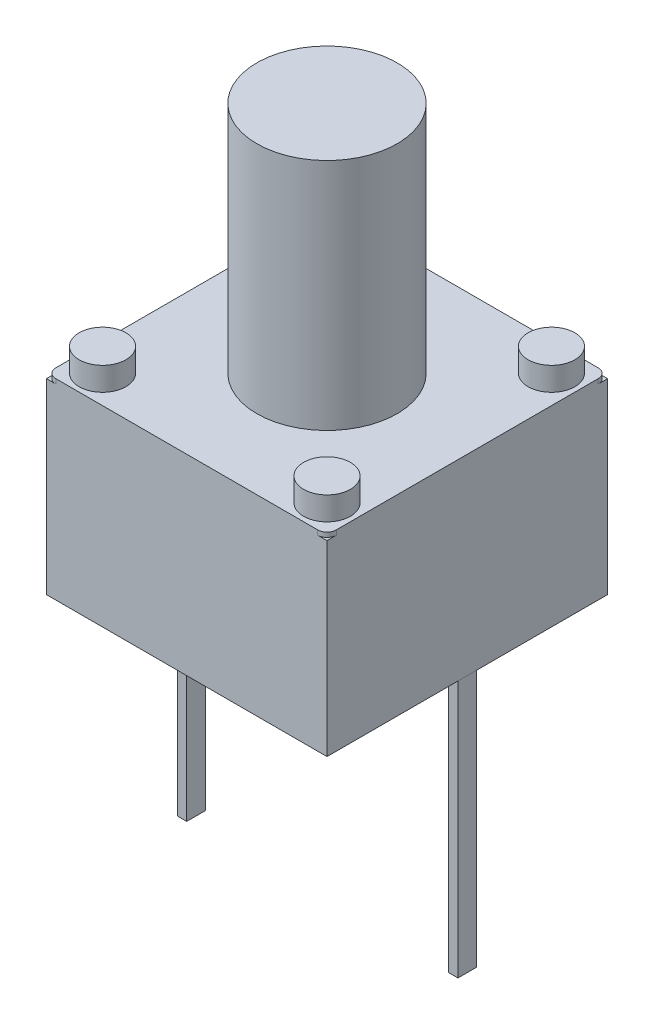
from build123d import *

# Parameters (mm, degrees)
SKETCH1_W             = 6
SKETCH1_H             = 6
BOSS_EXTRUDE1_DEPTH   = 4
BOSS_EXTRUDE2_DEPTH   = 0.1
SKETCH4_R             = 0.5
BOSS_EXTRUDE3_DEPTH   = 0.5
SKETCH5_R             = 1.5
BOSS_EXTRUDE4_DEPTH   = 5
SKETCH6_W             = 0.2
SKETCH6_H             = 0.4
BOSS_EXTRUDE5_DEPTH   = 5.5
BOSS_EXTRUDE5_2_DEPTH = 5.5


with BuildPart() as part:
    # Sketch1 → Boss-Extrude1 (new body)
    with BuildSketch(Plane(origin=(0, 0, 0), x_dir=(1, 0, 0), z_dir=(0, 1, 0))):
        with Locations((3, 3)):
            Rectangle(SKETCH1_W, SKETCH1_H)
    extrude(amount=BOSS_EXTRUDE1_DEPTH)

    # Sketch2 → Boss-Extrude2 (add)
    with BuildSketch(Plane(origin=(0, 4, 0), x_dir=(1, 0, 0), z_dir=(0, 1, 0))):
        with BuildLine():
            Line((0.2, 6), (5.8, 6))
            ThreePointArc((5.8, 6), (5.941421356, 5.941421356), (6, 5.8))
            Line((6, 5.8), (6, 0.2))
            ThreePointArc((6, 0.2), (5.941421356, 0.058578644), (5.8, 0))
            Line((5.8, 0), (0.2, 0))
            ThreePointArc((0.2, 0), (0.058578644, 0.058578644), (0, 0.2))
            Line((0, 0.2), (0, 5.8))
            ThreePointArc((0, 5.8), (0.058578644, 5.941421356), (0.2, 6))
        make_face()
    extrude(amount=BOSS_EXTRUDE2_DEPTH)

    # Sketch4 → Boss-Extrude3 (add)
    with BuildSketch(Plane(origin=(0, 4.1, 0), x_dir=(1, 0, 0), z_dir=(0, 1, 0))):
        with Locations((0.6, 5.4)):
            Circle(SKETCH4_R)
        with Locations((5.4, 5.4)):
            Circle(SKETCH4_R)
        with Locations((5.4, 0.6)):
            Circle(SKETCH4_R)
        with Locations((0.6, 0.6)):
            Circle(SKETCH4_R)
    extrude(amount=BOSS_EXTRUDE3_DEPTH)

    # Sketch5 → Boss-Extrude4 (add)
    with BuildSketch(Plane(origin=(0, 4.1, 0), x_dir=(1, 0, 0), z_dir=(0, 1, 0))):
        with Locations((3, 3)):
            Circle(SKETCH5_R)
    extrude(amount=BOSS_EXTRUDE4_DEPTH)


with BuildPart() as body_2:
    # Sketch6 → Boss-Extrude5 (new body)
    with BuildSketch(Plane.XZ):
        with Locations((0.1, -3)):
            Rectangle(SKETCH6_W, SKETCH6_H)
    extrude(amount=BOSS_EXTRUDE5_DEPTH)


with BuildPart() as body_3:
    # Sketch6 → Boss-Extrude5 2 (new body)
    with BuildSketch(Plane.XZ):
        with Locations((5.9, -3)):
            Rectangle(SKETCH6_W, SKETCH6_H)
    extrude(amount=BOSS_EXTRUDE5_2_DEPTH)


solid = Compound([part.part, body_2.part, body_3.part])
